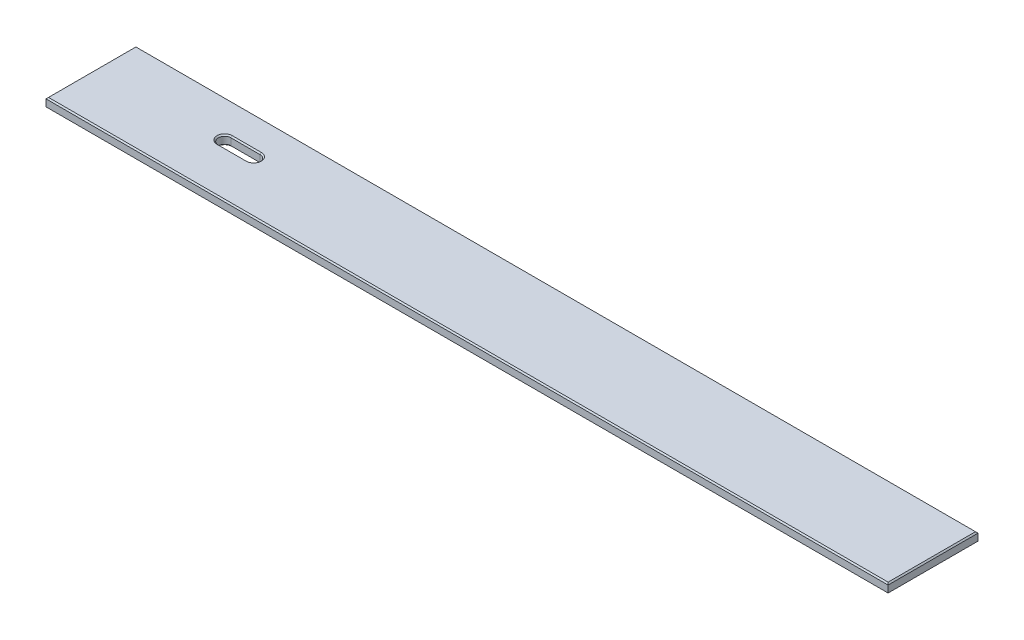
from build123d import *

# Parameters (mm, degrees)
SKETCH1_W           = 1695.45
SKETCH1_H           = 180.975
BOSS_EXTRUDE1_DEPTH = 19.05
CHAMFER1_SIZE       = 2.54
CHAMFER2_SIZE       = 2.54


with BuildPart() as part:
    # Sketch1 → Boss-Extrude1 (new body)
    with BuildSketch(Plane(origin=(0, 0, 0), x_dir=(1, 0, 0), z_dir=(0, 1, 0))):
        with Locations((847.725, 90.4875)):
            Rectangle(SKETCH1_W, SKETCH1_H)
        with BuildLine():
            Line((254, 118.25605), (312.7502, 118.25605))
            ThreePointArc((312.7502, 118.25605), (325.4502, 105.55605), (312.7502, 92.85605))
            Line((312.7502, 92.85605), (254, 92.85605))
            ThreePointArc((254, 92.85605), (241.3, 105.55605), (254, 118.25605))
        make_face(mode=Mode.SUBTRACT)
    extrude(amount=BOSS_EXTRUDE1_DEPTH)

    # Chamfer1
    chamfer1_edges = [part.edges().sort_by_distance(p)[0] for p in [
        (1695.45, 19.05, -90.4875),
        (325.4502, 19.05, -105.55605),
        (847.725, 19.05, -180.975),
        (283.3751, 19.05, -118.25605),
        (241.3, 19.05, -105.55605),
        (283.3751, 19.05, -92.85605),
        (0, 19.05, -90.4875),
        (847.725, 19.05, 0),
    ]]
    chamfer(chamfer1_edges, length=CHAMFER1_SIZE)

    # Chamfer2
    chamfer2_edges = [part.edges().sort_by_distance(p)[0] for p in [
        (325.4502, 0, -105.55605),
        (283.3751, 0, -118.25605),
        (241.3, 0, -105.55605),
        (283.3751, 0, -92.85605),
        (847.725, 0, -180.975),
        (1695.45, 0, -90.4875),
        (847.725, 0, 0),
        (0, 0, -90.4875),
    ]]
    chamfer(chamfer2_edges, length=CHAMFER2_SIZE)


solid = part.part
